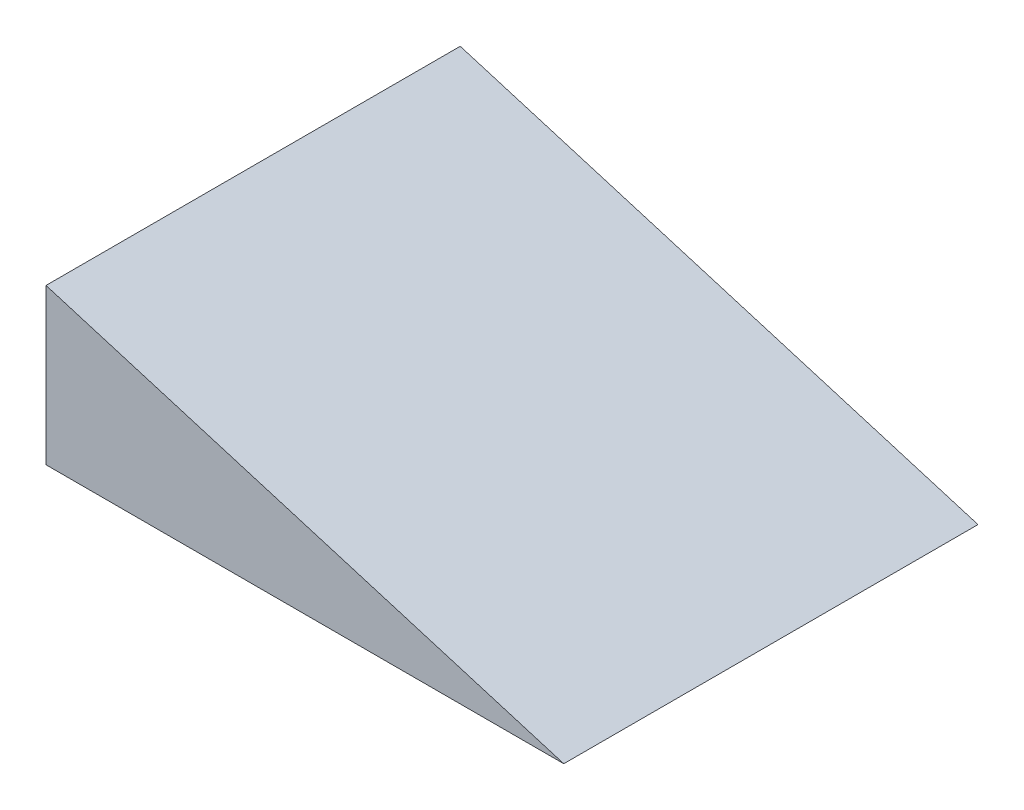
from build123d import *

# Parameters (mm, degrees)
BOSS_EXTRUDE1_DEPTH = 609.6
SHELL1_T            = -6.35


with BuildPart() as part:
    # Sketch1 → Boss-Extrude1 (new body)
    with BuildSketch(Plane.XY):
        Polygon((0, 228.6), (0, 0), (762, 0), align=None)
    extrude(amount=-BOSS_EXTRUDE1_DEPTH)

    # Shell1
    shell1_openings = [part.faces().sort_by_distance(p)[0] for p in [
        (0, 114.3, -304.8),
    ]]
    offset(amount=SHELL1_T, openings=shell1_openings, kind=Kind.INTERSECTION)


solid = part.part
